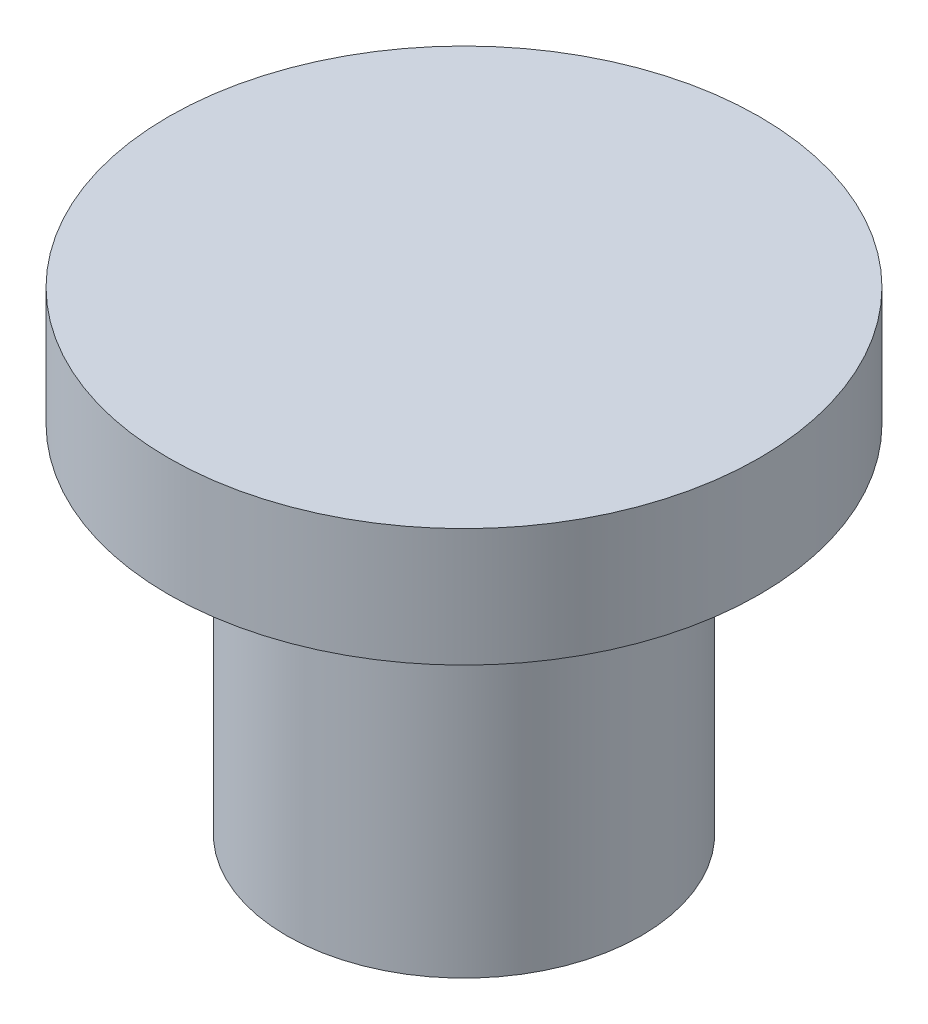
from build123d import *


with BuildPart() as part:
    # Эскиз1 → Повернуть1 (revolve)
    with BuildSketch(Plane.XY):
        Polygon((-5, 8), (-5, 6), (-3, 6), (-3, 0), (0, 0), (0, 8), align=None)
    revolve(axis=Axis((0, 14.588041347, 0), (0, -1, 0)))


solid = part.part
